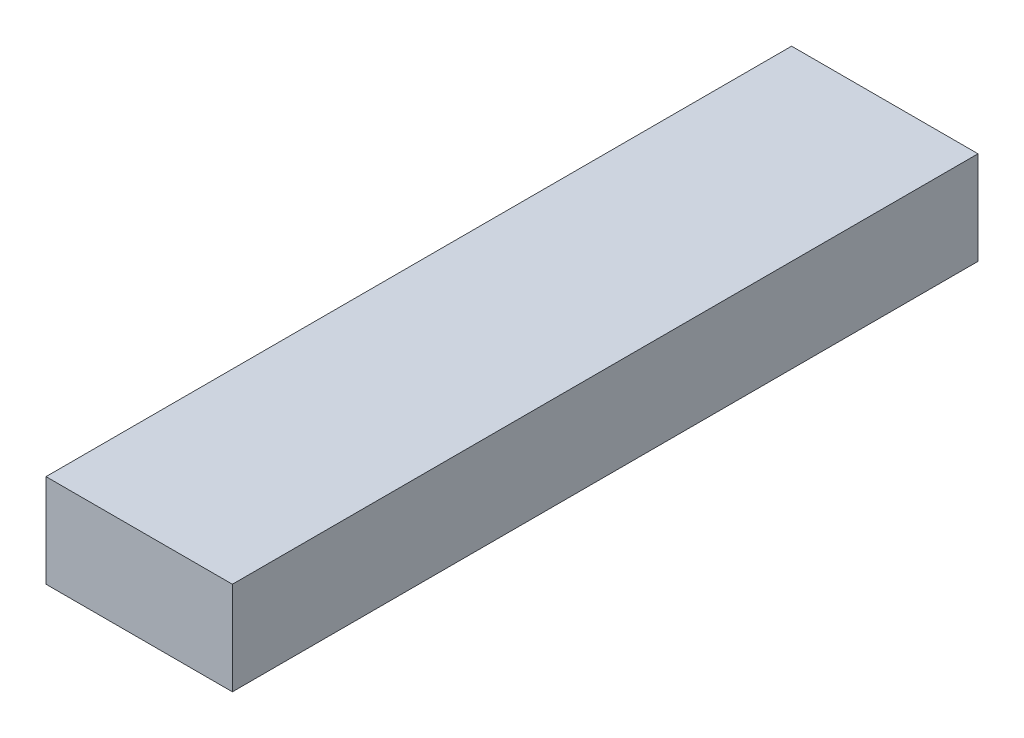
from build123d import *

# Parameters (mm, degrees)
SKETCH1_W           = 10
SKETCH1_H           = 5
BOSS_EXTRUDE1_DEPTH = 40


with BuildPart() as part:
    # Sketch1 → Boss-Extrude1 (new body)
    with BuildSketch(Plane.XY):
        Rectangle(SKETCH1_W, SKETCH1_H)
    extrude(amount=BOSS_EXTRUDE1_DEPTH)


solid = part.part
